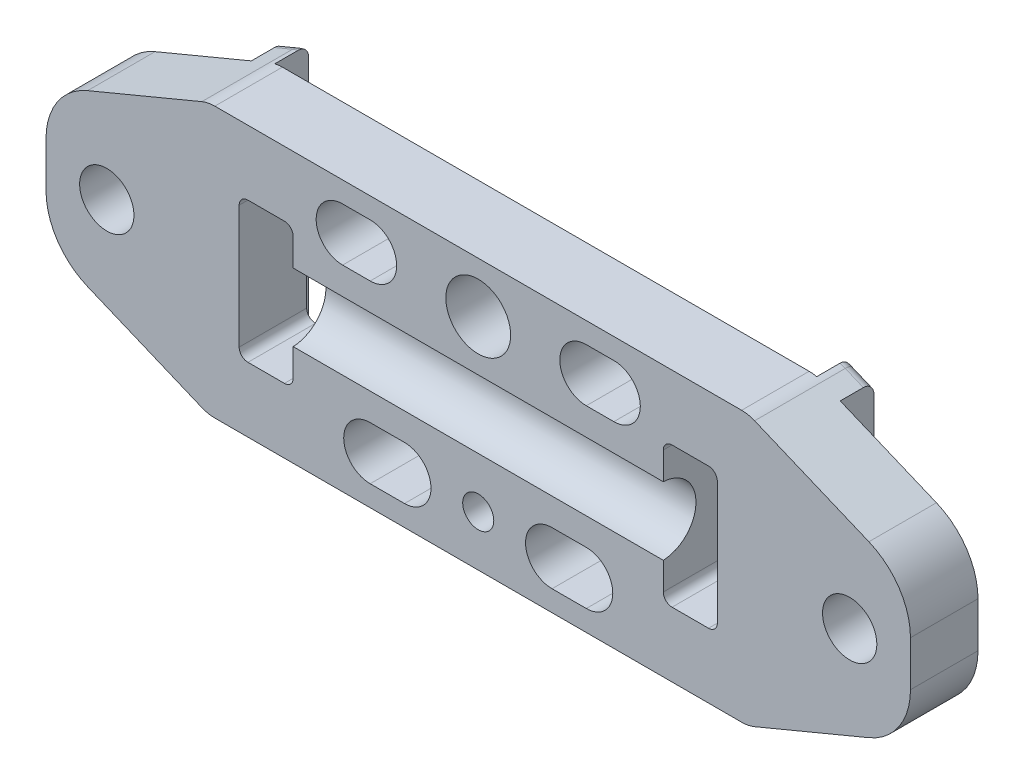
from build123d import *

# Parameters (mm, degrees)
BOSS_EXTRUDE1_DEPTH            = 6.35
BOSS_EXTRUDE2_DEPTH            = 3.175
BOSS_EXTRUDE3_DEPTH            = 3.175
CUT_EXTRUDE1_DEPTH             = 3.175
SKETCH5_W                      = 5.08
SKETCH5_H                      = 13.208
CUT_EXTRUDE2_DEPTH             = 7.35
SKETCH6_W                      = 5.08
SKETCH6_H                      = 13.208
CUT_EXTRUDE3_DEPTH             = 7.35
CUT_EXTRUDE4_REACH             = 60.039
CUT_EXTRUDE5_DEPTH             = 3.175
CUT_EXTRUDE6_DEPTH             = 7.35
CUT_EXTRUDE7_DEPTH             = 7.35
CUT_EXTRUDE8_DEPTH             = 7.35
CUT_EXTRUDE9_DEPTH             = 10.525
CUT_EXTRUDE10_DEPTH            = 2.032
F_12_CLEARANCE_HOLE1_D         = 6.096
F_12_CLEARANCE_HOLE1_DEPTH     = 4.953
F_3_CLEARANCE_HOLE1_D          = 2.921
F_3_CLEARANCE_HOLE1_DEPTH      = 9.525
F_7_0_201_DIAMETER_HOLE1_D     = 5.1054
F_7_0_201_DIAMETER_HOLE1_DEPTH = 9.525
FILLET1_R                      = 3.175
FILLET2_R                      = 0.8255
FILLET3_R                      = 1
FILLET4_R                      = 6.35


with BuildPart() as part:
    # Sketch1 → Boss-Extrude1 (new body)
    with BuildSketch(Plane(origin=(0, 0, 0), x_dir=(-1, 0, 0), z_dir=(0, 0, -1))):
        Polygon((-50.8, 863.6), (-66.04, 857.25), (-66.04, 844.55), (-50.8, 838.2), (0, 838.2), (15.24, 844.55), (15.24, 857.25), (0, 863.6), align=None)
    extrude(amount=-BOSS_EXTRUDE1_DEPTH)

    # Sketch2 → Boss-Extrude2 (add)
    with BuildSketch(Plane(origin=(0, 0, 0), x_dir=(-1, 0, 0), z_dir=(0, 0, -1))):
        Polygon((-50.8762, 838.23175), (-66.04, 844.55), (-66.04, 857.25), (-50.8762, 863.56825), align=None)
    extrude(amount=BOSS_EXTRUDE2_DEPTH)

    # Sketch3 → Boss-Extrude3 (add)
    with BuildSketch(Plane(origin=(0, 0, 0), x_dir=(-1, 0, 0), z_dir=(0, 0, -1))):
        Polygon((0.0762, 863.56825), (15.24, 857.25), (15.24, 844.55), (0.0762, 838.23175), align=None)
    extrude(amount=BOSS_EXTRUDE3_DEPTH)

    # Sketch4 → Cut-Extrude1 (cut)
    with BuildSketch(Plane(origin=(0, 0, -3.175), x_dir=(-1, 0, 0), z_dir=(0, 0, -1))):
        Polygon((2.286, 862.6475), (2.286, 839.1525), (15.24, 844.55), (15.24, 857.25), align=None)
    extrude(amount=-CUT_EXTRUDE1_DEPTH, mode=Mode.SUBTRACT)

    # Sketch5 → Cut-Extrude2 (cut, through all)
    with BuildSketch(Plane(origin=(0, 0, 0), x_dir=(-1, 0, 0), z_dir=(0, 0, -1))):
        with Locations((-5.461, 850.9)):
            Rectangle(SKETCH5_W, SKETCH5_H)
    extrude(amount=-CUT_EXTRUDE2_DEPTH, mode=Mode.SUBTRACT)

    # Sketch6 → Cut-Extrude3 (cut, through all)
    with BuildSketch(Plane(origin=(0, 0, 0), x_dir=(-1, 0, 0), z_dir=(0, 0, -1))):
        with Locations((-45.339, 850.9)):
            Rectangle(SKETCH6_W, SKETCH6_H)
    extrude(amount=-CUT_EXTRUDE3_DEPTH, mode=Mode.SUBTRACT)

    # Sketch7 → Cut-Extrude4 (cut, up to next)
    with BuildSketch(Plane.ZY.offset(-8.001), mode=Mode.PRIVATE) as cut_extrude4_sk1:
        with BuildLine():
            Line((6.35, 847.702120834), (6.35, 854.097879166))
            ThreePointArc((6.35, 854.097879166), (3.2766, 850.9), (6.35, 847.702120834))
        make_face()
    cut_extrude4_tool1 = extrude(cut_extrude4_sk1.sketch, amount=-CUT_EXTRUDE4_REACH, mode=Mode.PRIVATE) & part.part
    add(cut_extrude4_tool1.solids().sort_by_distance((8.001, 850.9, 5.049826))[0], mode=Mode.SUBTRACT)

    # Sketch8 → Cut-Extrude5 (cut)
    with BuildSketch(Plane(origin=(0, 0, -3.175), x_dir=(-1, 0, 0), z_dir=(0, 0, -1))):
        Polygon((-53.086, 839.1525), (-53.086, 862.6475), (-66.04, 857.25), (-66.04, 844.55), align=None)
    extrude(amount=-CUT_EXTRUDE5_DEPTH, mode=Mode.SUBTRACT)

    # Sketch9 → Cut-Extrude6 (cut, through all)
    with BuildSketch(Plane(origin=(0, 0, 0), x_dir=(-1, 0, 0), z_dir=(0, 0, -1))):
        with BuildLine():
            Line((-35.56, 840.1558), (-32.340549132, 840.1558))
            ThreePointArc((-32.340549132, 840.1558), (-29.851349132, 842.645), (-32.340549132, 845.1342))
            Line((-32.340549132, 845.1342), (-35.56, 845.1342))
            ThreePointArc((-35.56, 845.1342), (-38.0492, 842.645), (-35.56, 840.1558))
        make_face()
    extrude(amount=-CUT_EXTRUDE6_DEPTH, mode=Mode.SUBTRACT)

    # Sketch10 → Cut-Extrude7 (cut, through all)
    with BuildSketch(Plane(origin=(0, 0, 0), x_dir=(-1, 0, 0), z_dir=(0, 0, -1))):
        with BuildLine():
            Line((-35.56, 861.6442), (-38.1508, 861.6442))
            ThreePointArc((-38.1508, 861.6442), (-40.64, 859.155), (-38.1508, 856.6658))
            Line((-38.1508, 856.6658), (-35.56, 856.6658))
            ThreePointArc((-35.56, 856.6658), (-33.0708, 859.155), (-35.56, 861.6442))
        make_face()
    extrude(amount=-CUT_EXTRUDE7_DEPTH, mode=Mode.SUBTRACT)

    # Sketch11 → Cut-Extrude8 (cut, through all)
    with BuildSketch(Plane(origin=(0, 0, 0), x_dir=(-1, 0, 0), z_dir=(0, 0, -1))):
        with BuildLine():
            Line((-15.24, 845.1342), (-18.4658, 845.1342))
            ThreePointArc((-18.4658, 845.1342), (-20.955, 842.645), (-18.4658, 840.1558))
            Line((-18.4658, 840.1558), (-15.24, 840.1558))
            ThreePointArc((-15.24, 840.1558), (-12.7508, 842.645), (-15.24, 845.1342))
        make_face()
    extrude(amount=-CUT_EXTRUDE8_DEPTH, mode=Mode.SUBTRACT)

    # Sketch12 → Cut-Extrude9 (cut, through all)
    with BuildSketch(Plane.XY.offset(6.35)):
        with BuildLine():
            Line((15.24, 861.6442), (12.6492, 861.6442))
            ThreePointArc((12.6492, 861.6442), (10.16, 859.155), (12.6492, 856.6658))
            Line((12.6492, 856.6658), (15.24, 856.6658))
            ThreePointArc((15.24, 856.6658), (17.7292, 859.155), (15.24, 861.6442))
        make_face()
    extrude(amount=-CUT_EXTRUDE9_DEPTH, mode=Mode.SUBTRACT)

    # Sketch13 → Cut-Extrude10 (cut)
    with BuildSketch(Plane(origin=(0, 0, 0), x_dir=(-1, 0, 0), z_dir=(0, 0, -1))):
        with BuildLine():
            Line((-26.8605, 843.0006), (-23.940383746, 843.0006))
            Line((-23.940383746, 843.0006), (-23.940383746, 858.7994))
            ThreePointArc((-23.940383746, 858.7994), (-25.374596157, 860.310479047), (-26.8605, 858.8502))
            Line((-26.8605, 858.8502), (-26.8605, 843.0006))
        make_face()
    extrude(amount=-CUT_EXTRUDE10_DEPTH, mode=Mode.SUBTRACT)

    # #12 Clearance Hole1
    with Locations(Plane.XY.offset(6.35)):
        with Locations((25.4, 858.8502)):
            Hole(F_12_CLEARANCE_HOLE1_D / 2, depth=F_12_CLEARANCE_HOLE1_DEPTH)

    # #3 Clearance Hole1
    with Locations(Plane.XY.offset(6.35)):
        with Locations((25.4, 842.9498)):
            Hole(F_3_CLEARANCE_HOLE1_D / 2, depth=F_3_CLEARANCE_HOLE1_DEPTH)

    # #7 (0.201) Diameter Hole1
    with Locations(Plane.XY.offset(6.35)):
        with Locations((-9.525, 850.9), (60.325, 850.9)):
            Hole(F_7_0_201_DIAMETER_HOLE1_D / 2, depth=F_7_0_201_DIAMETER_HOLE1_DEPTH)

    # Fillet1
    fillet1_edges = [part.edges().sort_by_distance(p)[0] for p in [
        (0, 838.2, 3.175),
        (50.8, 838.2, 3.175),
        (50.8, 863.6, 3.175),
        (0, 863.6, 3.175),
    ]]
    fillet(fillet1_edges, radius=FILLET1_R)

    # Fillet2
    fillet2_edges = [part.edges().sort_by_distance(p)[0] for p in [
        (8.001, 857.504, 3.175),
        (2.921, 857.504, 3.175),
        (2.921, 844.296, 3.175),
        (8.001, 844.296, 3.175),
        (47.879, 857.504, 3.175),
        (42.799, 857.504, 3.175),
        (42.799, 844.296, 3.175),
        (47.879, 844.296, 3.175),
    ]]
    fillet(fillet2_edges, radius=FILLET2_R)

    # Fillet3
    fillet3_edges = [part.edges().sort_by_distance(p)[0] for p in [
        (52.236076923, 838.798365385, -3.175),
        (-1.436076923, 838.798365385, -3.175),
        (-0.334631427, 863.448316043, -3.175),
        (-0.334631427, 838.351683957, -3.175),
        (52.236076923, 863.001634615, -3.175),
        (51.134631427, 863.448316043, -3.175),
        (51.134631427, 838.351683957, -3.175),
        (-1.436076923, 863.001634615, -3.175),
    ]]
    fillet(fillet3_edges, radius=FILLET3_R)

    # Fillet4
    fillet4_edges = [part.edges().sort_by_distance(p)[0] for p in [
        (-15.24, 857.25, 3.175),
        (-15.24, 844.55, 3.175),
        (66.04, 844.55, 3.175),
        (66.04, 857.25, 3.175),
    ]]
    fillet(fillet4_edges, radius=FILLET4_R)


solid = part.part
